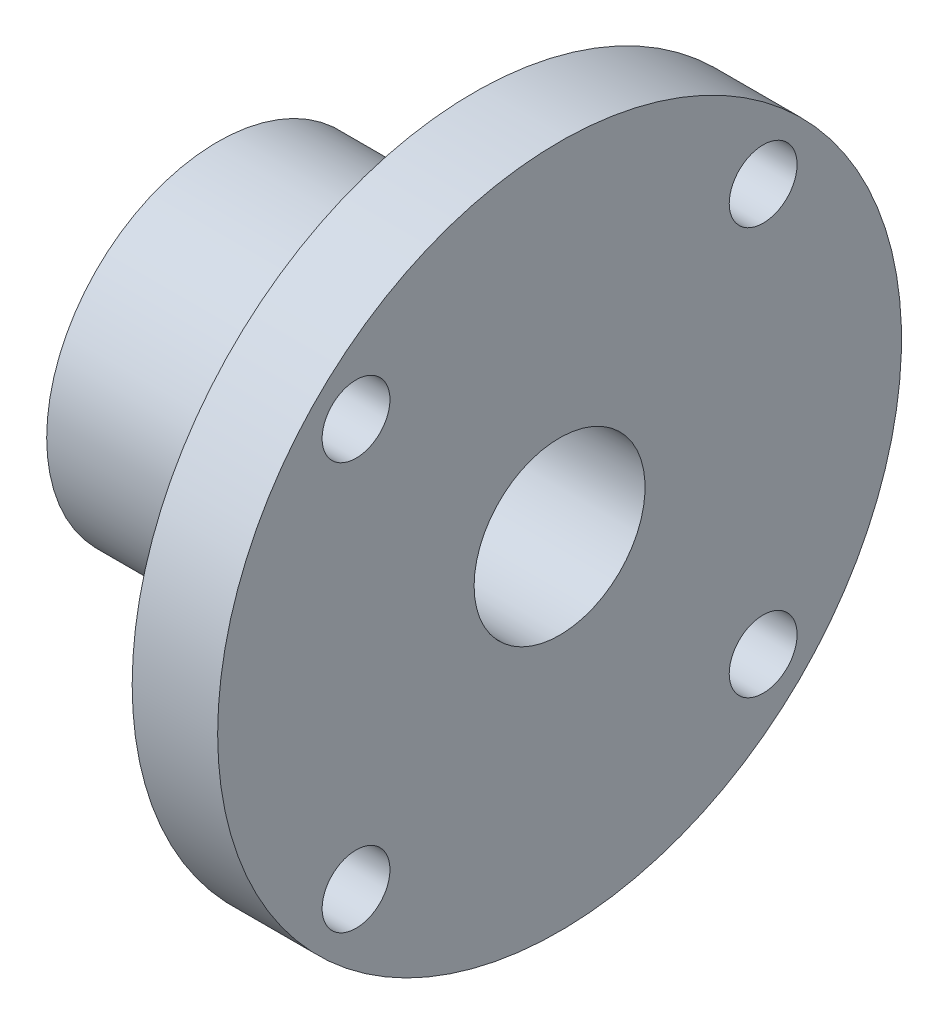
from build123d import *

# Parameters (mm, degrees)
CUT_EXTRUDE1_REACH = 6
SKETCH3_R          = 1.5875


with BuildPart() as part:
    # Sketch2 → Revolve1 (revolve)
    with BuildSketch(Plane.XY):
        Polygon((-16, -4), (0, -4), (0, -16.000000004), (-4, -16.000000004), (-4, -8), (-16, -8), align=None)
    revolve(axis=Axis((-12.310421286, 0, 0), (1, 0, 0)))

    # Sketch3 → Cut-Extrude1 (cut, up to next)
    with BuildSketch(Plane.ZY.offset(4), mode=Mode.PRIVATE) as cut_extrude1_sk1:
        with Locations((-9.525, 9.525)):
            Circle(SKETCH3_R)
    cut_extrude1_tool1 = extrude(cut_extrude1_sk1.sketch, amount=-CUT_EXTRUDE1_REACH, mode=Mode.PRIVATE) & part.part
    add(cut_extrude1_tool1.solids().sort_by_distance((-4, 9.525, -9.525))[0], mode=Mode.SUBTRACT)
    # Sketch3 → Cut-Extrude1 (cut, up to next)
    with BuildSketch(Plane.ZY.offset(4), mode=Mode.PRIVATE) as cut_extrude1_sk2:
        with Locations((-9.525, -9.525)):
            Circle(SKETCH3_R)
    cut_extrude1_tool2 = extrude(cut_extrude1_sk2.sketch, amount=-CUT_EXTRUDE1_REACH, mode=Mode.PRIVATE) & part.part
    add(cut_extrude1_tool2.solids().sort_by_distance((-4, -9.525, -9.525))[0], mode=Mode.SUBTRACT)
    # Sketch3 → Cut-Extrude1 (cut, up to next)
    with BuildSketch(Plane.ZY.offset(4), mode=Mode.PRIVATE) as cut_extrude1_sk3:
        with Locations((9.525, -9.525)):
            Circle(SKETCH3_R)
    cut_extrude1_tool3 = extrude(cut_extrude1_sk3.sketch, amount=-CUT_EXTRUDE1_REACH, mode=Mode.PRIVATE) & part.part
    add(cut_extrude1_tool3.solids().sort_by_distance((-4, -9.525, 9.525))[0], mode=Mode.SUBTRACT)
    # Sketch3 → Cut-Extrude1 (cut, up to next)
    with BuildSketch(Plane.ZY.offset(4), mode=Mode.PRIVATE) as cut_extrude1_sk4:
        with Locations((9.525, 9.525)):
            Circle(SKETCH3_R)
    cut_extrude1_tool4 = extrude(cut_extrude1_sk4.sketch, amount=-CUT_EXTRUDE1_REACH, mode=Mode.PRIVATE) & part.part
    add(cut_extrude1_tool4.solids().sort_by_distance((-4, 9.525, 9.525))[0], mode=Mode.SUBTRACT)


solid = part.part
